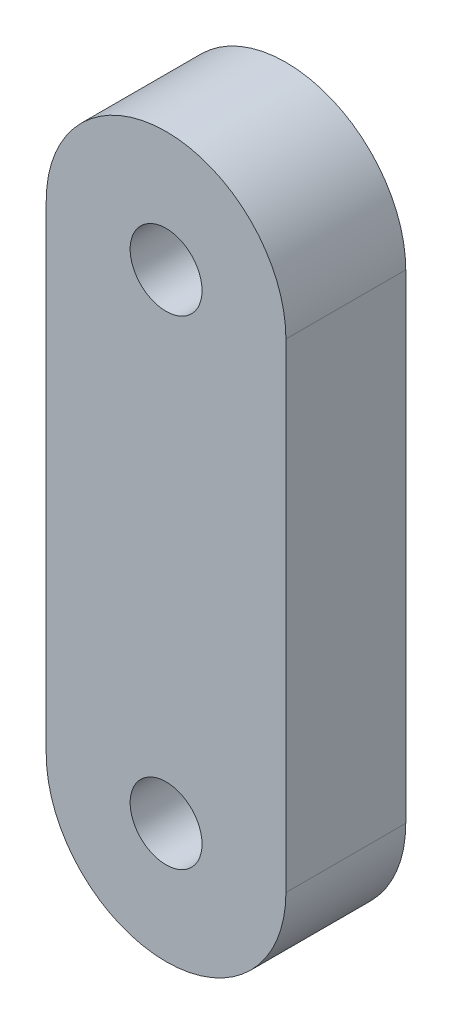
from build123d import *

# Parameters (mm, degrees)
EXTRUDE_1_DEPTH = 1


with BuildPart() as part:
    # 草图1 → 凸台-拉伸1 (new body)
    with BuildSketch(Plane.XY):
        with BuildLine():
            ThreePointArc((-0.3, 2), (0, 2.3), (0.3, 2))
            Line((0.3, 2), (1, 2))
            ThreePointArc((1, 2), (0, 3), (-1, 2))
            Line((-1, 2), (-0.3, 2))
        make_face()
        with BuildLine():
            Line((1, 2), (0.3, 2))
            ThreePointArc((0.3, 2), (0, 1.7), (-0.3, 2))
            Line((-0.3, 2), (-1, 2))
            ThreePointArc((-1, 2), (0, 1), (1, 2))
        make_face()
        with BuildLine():
            Line((1, -2), (1, 2))
            ThreePointArc((1, 2), (0, 1), (-1, 2))
            Line((-1, 2), (-1, -2))
            ThreePointArc((-1, -2), (0, -1), (1, -2))
        make_face()
        with BuildLine():
            ThreePointArc((-1, -2), (0, -3), (1, -2))
            Line((1, -2), (0.3, -2))
            ThreePointArc((0.3, -2), (0, -2.3), (-0.3, -2))
            Line((-0.3, -2), (-1, -2))
        make_face()
        with BuildLine():
            Line((0.3, -2), (1, -2))
            ThreePointArc((1, -2), (0, -1), (-1, -2))
            Line((-1, -2), (-0.3, -2))
            ThreePointArc((-0.3, -2), (0, -1.7), (0.3, -2))
        make_face()
    extrude(amount=EXTRUDE_1_DEPTH)


solid = part.part
